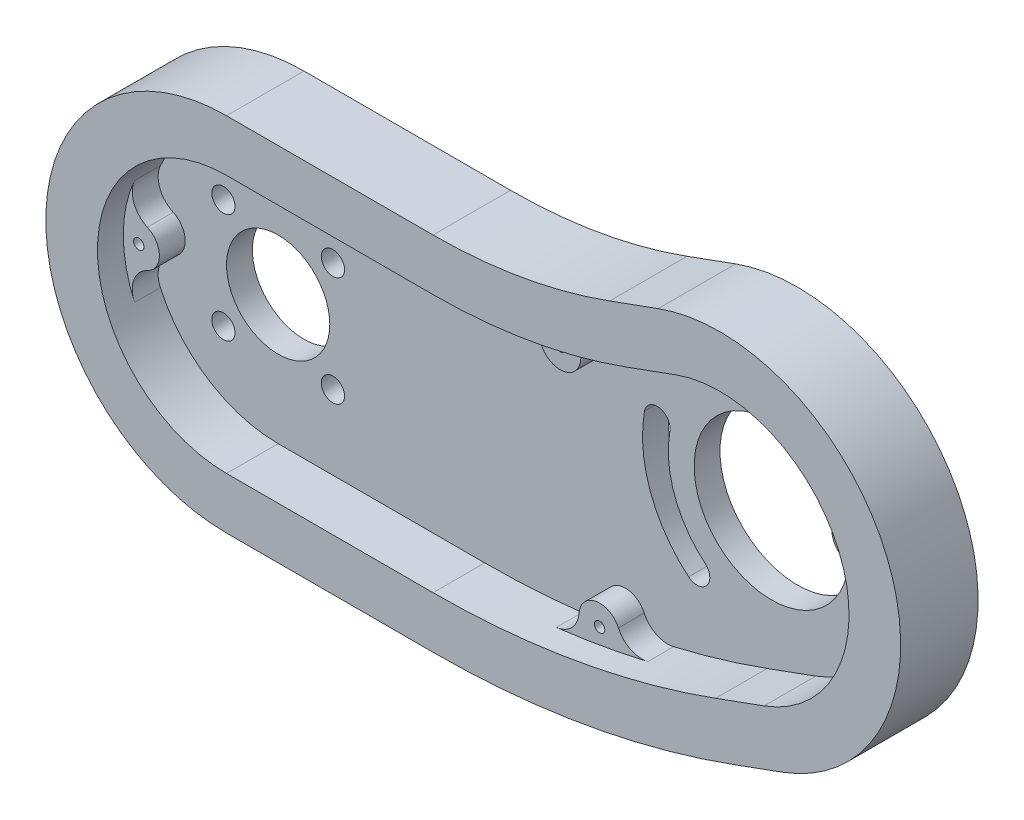
from build123d import *

# Parameters (mm, degrees)
EXTRUDE_1_DEPTH     = 20
CHAMFER_1_SIZE      = 10
CUT_EXTRUDE_1_DEPTH = 15
SKETCH_3_R          = 15
CUT_EXTRUDE_2_DEPTH = 20
SKETCH_4_R          = 2.25
SKETCH_4_R_2        = 10
CUT_EXTRUDE_3_DEPTH = 20
SKETCH_5_R          = 4
EXTRUDE_3_DEPTH     = 5
FILLET_1_R          = 5
SKETCH_6_R          = 1
CUT_EXTRUDE_4_DEPTH = 10
FILLET_2_R          = 5
CUT_EXTRUDE_5_REACH = 22
EXTRUDE_4_DEPTH     = 13
CUT_EXTRUDE_6_DEPTH = 5


with BuildPart() as part:
    # 스케치1 → 보스-돌출1 (new body)
    with BuildSketch(Plane.XY):
        with BuildLine():
            Line((0, 35), (40, 35))
            ThreePointArc((40, 35), (57.364817767, 36.519224699), (74.202014333, 41.030737921))
            Line((74.202014333, 41.030737921), (83.59894054, 44.450939355))
            ThreePointArc((83.59894054, 44.450939355), (128.458887284, 23.532402644), (107.540350573, -21.3275441))
            Line((107.540350573, -21.3275441), (98.143424365, -24.747745534))
            ThreePointArc((98.143424365, -24.747745534), (69.520190203, -32.417318012), (40, -35))
            Line((40, -35), (0, -35))
            ThreePointArc((0, -35), (-35, 0), (0, 35))
        make_face()
    extrude(amount=EXTRUDE_1_DEPTH)

    # 모따기1
    chamfer_1_edges = [part.edges().sort_by_distance(p)[0] for p in [
        (128.458887284, 23.532402644, 20),
        (78.900477436, 42.740838638, 20),
        (57.364817767, 36.519224699, 20),
        (20, 35, 20),
        (-35, 0, 20),
        (20, -35, 20),
        (69.520190203, -32.417318012, 20),
        (102.841887469, -23.037644817, 20),
    ]]
    chamfer(chamfer_1_edges, length=CHAMFER_1_SIZE)

    # 스케치2 → 컷-돌출1 (cut)
    with BuildSketch(Plane.XY.offset(20)):
        with BuildLine():
            Line((40, 25), (0, 25))
            ThreePointArc((0, 25), (-25, 0), (0, -25))
            Line((0, -25), (40, -25))
            ThreePointArc((40, -25), (67.783708427, -22.569240482), (94.723222932, -15.350819326))
            Line((94.723222932, -15.350819326), (104.12014914, -11.930617892))
            ThreePointArc((104.12014914, -11.930617892), (119.061961076, 20.11220121), (87.019141974, 35.054013147))
            Line((87.019141974, 35.054013147), (77.622215766, 31.633811714))
            ThreePointArc((77.622215766, 31.633811714), (59.101299543, 26.671147169), (40, 25))
        make_face()
    extrude(amount=-CUT_EXTRUDE_1_DEPTH, mode=Mode.SUBTRACT)

    # 스케치3 → 컷-돌출2 (cut)
    with BuildSketch(Plane.XY.offset(5)):
        with Locations((95.569645557, 11.561697627)):
            Circle(SKETCH_3_R)
    extrude(amount=-CUT_EXTRUDE_2_DEPTH, mode=Mode.SUBTRACT)

    # 스케치4 → 컷-돌출3 (cut)
    with BuildSketch(Plane.XY.offset(5)):
        with Locations((-10.606601718, 10.606601718)):
            Circle(SKETCH_4_R)
        with Locations((10.606601718, 10.606601718)):
            Circle(SKETCH_4_R)
        with Locations((10.606601718, -10.606601718)):
            Circle(SKETCH_4_R)
        with Locations((-10.606601718, -10.606601718)):
            Circle(SKETCH_4_R)
        Circle(SKETCH_4_R_2)
    extrude(amount=-CUT_EXTRUDE_3_DEPTH, mode=Mode.SUBTRACT)

    # 스케치5 → 보스-돌출3 (add)
    with BuildSketch(Plane.XY.offset(5)):
        with Locations((-22, 0)):
            Circle(SKETCH_5_R)
        with Locations((116.242883214, 19.08614078)):
            Circle(SKETCH_5_R)
        with Locations((59.622244076, 23.71672391)):
            Circle(SKETCH_5_R)
        with Locations((67.262763894, -19.614817223)):
            Circle(SKETCH_5_R)
    extrude(amount=EXTRUDE_3_DEPTH)

    # 필렛1
    fillet_1_edges = [part.edges().sort_by_distance(p)[0] for p in [
        (-24.840909091, -2.81588983, 7.5),
        (-24.840909091, 2.81588983, 7.5),
        (117.94937348, 22.703859809, 7.5),
        (119.875555567, 17.41171802, 7.5),
        (61.666476802, 27.154908396, 7.5),
        (56.525365318, 26.248391731, 7.5),
        (70.410078123, -22.083503744, 7.5),
        (65.149596455, -23.011068594, 7.5),
    ]]
    fillet(fillet_1_edges, radius=FILLET_1_R)

    # 스케치6 → 컷-돌출4 (cut)
    with BuildSketch(Plane.XY.offset(10)):
        with Locations((59.622244076, 23.71672391)):
            Circle(SKETCH_6_R)
        with Locations((67.262763894, -19.614817223)):
            Circle(SKETCH_6_R)
        with Locations((-22, 0)):
            Circle(SKETCH_6_R)
        with Locations((116.242883214, 19.08614078)):
            Circle(SKETCH_6_R)
    extrude(amount=-CUT_EXTRUDE_4_DEPTH, mode=Mode.SUBTRACT)

    # 필렛2
    fillet_2_edges = [part.edges().sort_by_distance(p)[0] for p in [
        (128.458887284, 23.532402644, 10),
        (78.900477436, 42.740838638, 10),
        (102.841887469, -23.037644817, 10),
        (57.364817767, 36.519224699, 10),
        (69.520190203, -32.417318012, 10),
        (20, 35, 10),
        (20, -35, 10),
        (-35, 0, 10),
    ]]
    fillet(fillet_2_edges, radius=FILLET_2_R)

    # 스케치8 → 컷-돌출5 (cut, up to next)
    with BuildSketch(Plane(origin=(0, 0, 0), x_dir=(-1, 0, 0), z_dir=(0, 0, -1)), mode=Mode.PRIVATE) as cut_extrude_5_sk1:
        with BuildLine():
            ThreePointArc((-79.499955315, -7.589413451), (-72.077330037, 3.011194044), (-70.949451732, 15.902902069))
            ThreePointArc((-70.949451732, 15.902902069), (-73.845591558, 17.930801007), (-75.873490497, 15.03466118))
            ThreePointArc((-75.873490497, 15.03466118), (-76.775793141, 4.721294761), (-82.713893363, -3.759191235))
            ThreePointArc((-82.713893363, -3.759191235), (-83.022035447, -7.281271367), (-79.499955315, -7.589413451))
        make_face()
    cut_extrude_5_tool1 = extrude(cut_extrude_5_sk1.sketch, amount=-CUT_EXTRUDE_5_REACH, mode=Mode.PRIVATE) & part.part
    add(cut_extrude_5_tool1.solids().sort_by_distance((75.648018, 4.310818, 0))[0], mode=Mode.SUBTRACT)

    # 스케치9 → 보스-돌출4 (add)
    with BuildSketch(Plane(origin=(0, 0, 20), x_dir=(-1, 0, 0), z_dir=(0, 0, -1))):
        with BuildLine():
            Line((-107.540350573, -21.3275441), (-98.143424365, -24.747745534))
            ThreePointArc((-98.143424365, -24.747745534), (-69.520190203, -32.417318012), (-40, -35))
            Line((-40, -35), (0, -35))
            ThreePointArc((0, -35), (35, 0), (0, 35))
            Line((0, 35), (-40, 35))
            ThreePointArc((-40, 35), (-57.364817767, 36.519224699), (-74.202014333, 41.030737921))
            Line((-74.202014333, 41.030737921), (-83.59894054, 44.450939355))
            ThreePointArc((-83.59894054, 44.450939355), (-128.458887284, 23.532402644), (-107.540350573, -21.3275441))
        make_face()
        with BuildLine():
            Line((-104.12014914, -11.930617892), (-94.723222932, -15.350819326))
            ThreePointArc((-94.723222932, -15.350819326), (-67.783708427, -22.569240482), (-40, -25))
            Line((-40, -25), (0, -25))
            ThreePointArc((0, -25), (13.589095993, -20.984195722), (22.8125, -10.226917607))
            ThreePointArc((22.8125, -10.226917607), (25, 0), (22.8125, 10.226917607))
            ThreePointArc((22.8125, 10.226917607), (13.589095993, 20.984195722), (0, 25))
            Line((0, 25), (-40, 25))
            ThreePointArc((-40, 25), (-59.101299543, 26.671147169), (-77.622215766, 31.633811714))
            Line((-77.622215766, 31.633811714), (-87.019141974, 35.054013147))
            ThreePointArc((-87.019141974, 35.054013147), (-119.061961076, 20.11220121), (-104.12014914, -11.930617892))
        make_face(mode=Mode.SUBTRACT)
    extrude(amount=EXTRUDE_4_DEPTH)

    # 스케치10 → 컷-돌출6 (cut)
    with BuildSketch(Plane(origin=(0, 0, 20), x_dir=(-1, 0, 0), z_dir=(0, 0, -1))):
        with BuildLine():
            Line((-74.202014333, 41.030737921), (-83.59894054, 44.450939355))
            ThreePointArc((-83.59894054, 44.450939355), (-128.458887284, 23.532402644), (-107.540350573, -21.3275441))
            Line((-107.540350573, -21.3275441), (-98.143424365, -24.747745534))
            ThreePointArc((-98.143424365, -24.747745534), (-69.520190203, -32.417318012), (-40, -35))
            Line((-40, -35), (0, -35))
            ThreePointArc((0, -35), (35, 0), (0, 35))
            Line((0, 35), (-40, 35))
            ThreePointArc((-40, 35), (-57.364817767, 36.519224699), (-74.202014333, 41.030737921))
        make_face()
        with BuildLine():
            Line((-40, -25), (0, -25))
            ThreePointArc((0, -25), (25, 0), (0, 25))
            Line((0, 25), (-40, 25))
            ThreePointArc((-40, 25), (-59.101299543, 26.671147169), (-77.622215766, 31.633811714))
            Line((-77.622215766, 31.633811714), (-87.019141974, 35.054013147))
            ThreePointArc((-87.019141974, 35.054013147), (-119.061961076, 20.11220121), (-104.12014914, -11.930617892))
            Line((-104.12014914, -11.930617892), (-94.723222932, -15.350819326))
            ThreePointArc((-94.723222932, -15.350819326), (-67.783708427, -22.569240482), (-40, -25))
        make_face(mode=Mode.SUBTRACT)
    extrude(amount=CUT_EXTRUDE_6_DEPTH, mode=Mode.SUBTRACT)


solid = part.part
